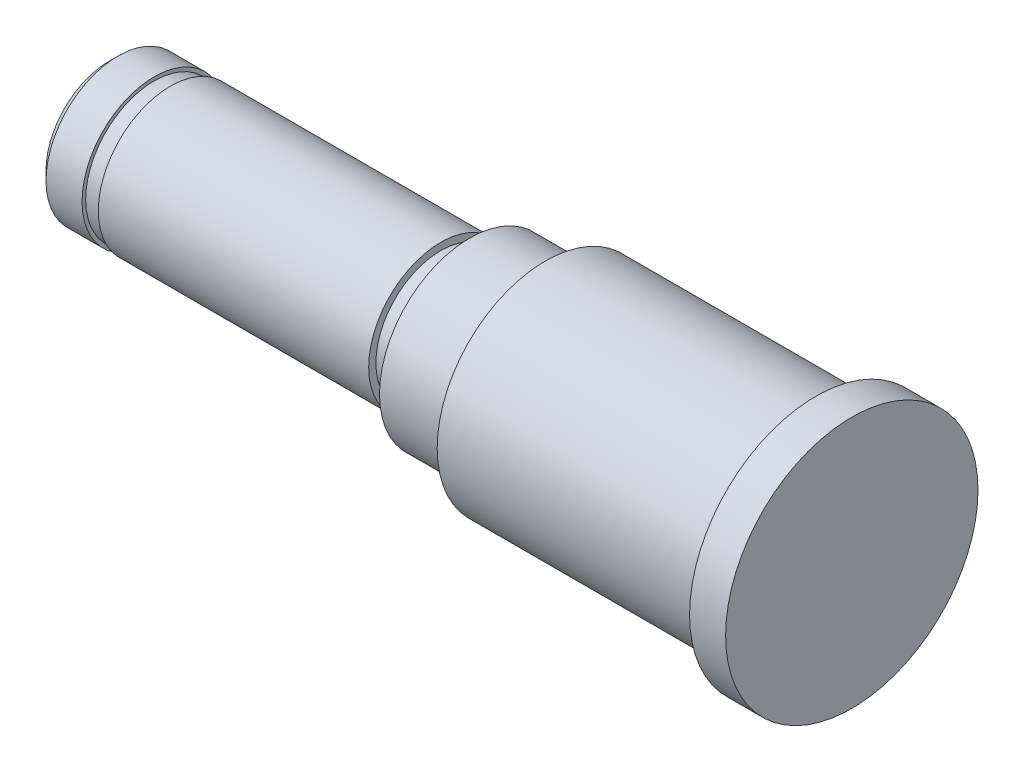
from build123d import *


with BuildPart() as part:
    # 草图1 → 旋转1 (revolve)
    with BuildSketch(Plane.XY):
        with BuildLine():
            Line((-70.913736012, 0), (-70.913736012, 3.5))
            Line((-70.913736012, 3.5), (-70.413736012, 4))
            Line((-70.413736012, 4), (-68.413986014, 4))
            Line((-68.413986014, 4), (-68.413986014, 3.8))
            Line((-68.413986014, 3.8), (-67.513986014, 3.8))
            Line((-67.513986014, 3.8), (-67.513986014, 4))
            Line((-67.513986014, 4), (-52.513986014, 4))
            Line((-52.513986014, 4), (-52.513986014, 3.6))
            Line((-52.513986014, 3.6), (-50.913986014, 3.6))
            Line((-50.913986014, 3.6), (-50.913986014, 4.1))
            Line((-50.913986014, 4.1), (-50.913986014, 5))
            Line((-50.913986014, 5), (-46.913986014, 5))
            ThreePointArc((-46.913986014, 5), (-46.772564658, 5.058578644), (-46.713986014, 5.2))
            Line((-46.713986014, 5.2), (-46.713986014, 6))
            Line((-46.713986014, 6), (-31.913986014, 6))
            ThreePointArc((-31.913986014, 6), (-31.772564658, 6.058578644), (-31.713986014, 6.2))
            Line((-31.713986014, 6.2), (-31.713986014, 7))
            Line((-31.713986014, 7), (-29.713986014, 7))
            Line((-29.713986014, 7), (-29.713986014, 0))
            Line((-29.713986014, 0), (-70.913736012, 0))
        make_face()
    revolve(axis=Axis((-99.953379953, 0, 0), (1, 0, 0)))


solid = part.part
